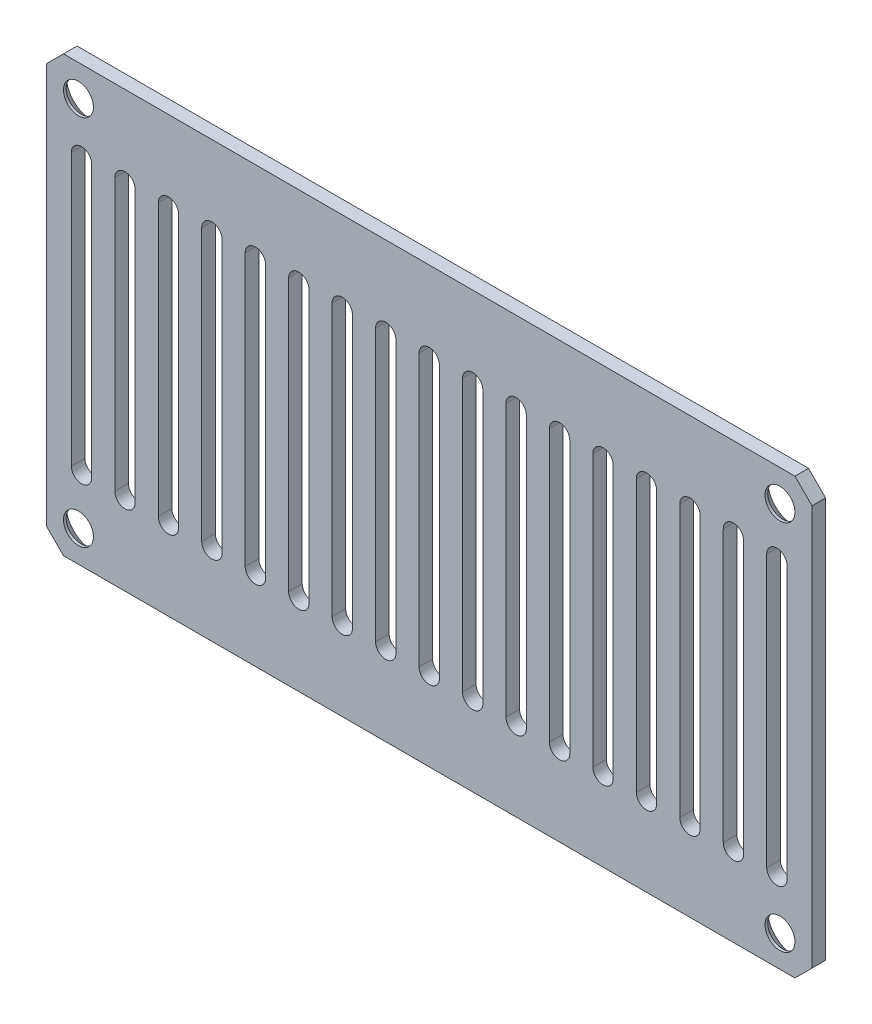
from build123d import *

# Parameters (mm, degrees)
SKETCH1_W           = 89.5
SKETCH1_H           = 50.8
BOSS_EXTRUDE1_DEPTH = 1.5875
CHAMFER1_SIZE       = 2
CUT_EXTRUDE1_DEPTH  = 2.5875
SKETCH3_R           = 1.75
CUT_EXTRUDE2_DEPTH  = 2.5875
CHAMFER2_SIZE       = 1.27


with BuildPart() as part:
    # Sketch1 → Boss-Extrude1 (new body)
    with BuildSketch(Plane.XY):
        with Locations((44.75, 25.4)):
            Rectangle(SKETCH1_W, SKETCH1_H)
    extrude(amount=BOSS_EXTRUDE1_DEPTH)

    # Chamfer1
    chamfer1_edges = [part.edges().sort_by_distance(p)[0] for p in [
        (0, 50.8, 0.79375),
        (89.5, 50.8, 0.79375),
        (89.5, 0, 0.79375),
        (0, 0, 0.79375),
    ]]
    chamfer(chamfer1_edges, length=CHAMFER1_SIZE)

    # Sketch2 → Cut-Extrude1 (cut, through all)
    with BuildSketch(Plane(origin=(0, 0, 0), x_dir=(-1, 0, 0), z_dir=(0, 0, -1))):
        with BuildLine():
            Line((-43.559375, 41.275), (-43.559375, 9.525))
            ThreePointArc((-43.559375, 9.525), (-44.75, 8.334375), (-45.940625, 9.525))
            Line((-45.940625, 9.525), (-45.940625, 41.275))
            ThreePointArc((-45.940625, 41.275), (-44.75, 42.465625), (-43.559375, 41.275))
        make_face()
        with BuildLine():
            Line((-38.479375, 41.275), (-38.479375, 9.525))
            ThreePointArc((-38.479375, 9.525), (-39.67, 8.334375), (-40.860625, 9.525))
            Line((-40.860625, 9.525), (-40.860625, 41.275))
            ThreePointArc((-40.860625, 41.275), (-39.67, 42.465625), (-38.479375, 41.275))
        make_face()
        with BuildLine():
            Line((-33.399375, 41.275), (-33.399375, 9.525))
            ThreePointArc((-33.399375, 9.525), (-34.59, 8.334375), (-35.780625, 9.525))
            Line((-35.780625, 9.525), (-35.780625, 41.275))
            ThreePointArc((-35.780625, 41.275), (-34.59, 42.465625), (-33.399375, 41.275))
        make_face()
        with BuildLine():
            Line((-28.319375, 41.275), (-28.319375, 9.525))
            ThreePointArc((-28.319375, 9.525), (-29.51, 8.334375), (-30.700625, 9.525))
            Line((-30.700625, 9.525), (-30.700625, 41.275))
            ThreePointArc((-30.700625, 41.275), (-29.51, 42.465625), (-28.319375, 41.275))
        make_face()
        with BuildLine():
            Line((-23.239375, 41.275), (-23.239375, 9.525))
            ThreePointArc((-23.239375, 9.525), (-24.43, 8.334375), (-25.620625, 9.525))
            Line((-25.620625, 9.525), (-25.620625, 41.275))
            ThreePointArc((-25.620625, 41.275), (-24.43, 42.465625), (-23.239375, 41.275))
        make_face()
        with BuildLine():
            Line((-18.159375, 41.275), (-18.159375, 9.525))
            ThreePointArc((-18.159375, 9.525), (-19.35, 8.334375), (-20.540625, 9.525))
            Line((-20.540625, 9.525), (-20.540625, 41.275))
            ThreePointArc((-20.540625, 41.275), (-19.35, 42.465625), (-18.159375, 41.275))
        make_face()
        with BuildLine():
            Line((-13.079375, 41.275), (-13.079375, 9.525))
            ThreePointArc((-13.079375, 9.525), (-14.27, 8.334375), (-15.460625, 9.525))
            Line((-15.460625, 9.525), (-15.460625, 41.275))
            ThreePointArc((-15.460625, 41.275), (-14.27, 42.465625), (-13.079375, 41.275))
        make_face()
        with BuildLine():
            Line((-7.999375, 41.275), (-7.999375, 9.525))
            ThreePointArc((-7.999375, 9.525), (-9.19, 8.334375), (-10.380625, 9.525))
            Line((-10.380625, 9.525), (-10.380625, 41.275))
            ThreePointArc((-10.380625, 41.275), (-9.19, 42.465625), (-7.999375, 41.275))
        make_face()
        with BuildLine():
            Line((-2.919375, 41.275), (-2.919375, 9.525))
            ThreePointArc((-2.919375, 9.525), (-4.11, 8.334375), (-5.300625, 9.525))
            Line((-5.300625, 9.525), (-5.300625, 41.275))
            ThreePointArc((-5.300625, 41.275), (-4.11, 42.465625), (-2.919375, 41.275))
        make_face()
        with BuildLine():
            Line((-48.639375, 41.275), (-48.639375, 9.525))
            ThreePointArc((-48.639375, 9.525), (-49.83, 8.334375), (-51.020625, 9.525))
            Line((-51.020625, 9.525), (-51.020625, 41.275))
            ThreePointArc((-51.020625, 41.275), (-49.83, 42.465625), (-48.639375, 41.275))
        make_face()
        with BuildLine():
            Line((-53.719375, 41.275), (-53.719375, 9.525))
            ThreePointArc((-53.719375, 9.525), (-54.91, 8.334375), (-56.100625, 9.525))
            Line((-56.100625, 9.525), (-56.100625, 41.275))
            ThreePointArc((-56.100625, 41.275), (-54.91, 42.465625), (-53.719375, 41.275))
        make_face()
        with BuildLine():
            Line((-58.799375, 41.275), (-58.799375, 9.525))
            ThreePointArc((-58.799375, 9.525), (-59.99, 8.334375), (-61.180625, 9.525))
            Line((-61.180625, 9.525), (-61.180625, 41.275))
            ThreePointArc((-61.180625, 41.275), (-59.99, 42.465625), (-58.799375, 41.275))
        make_face()
        with BuildLine():
            Line((-63.879375, 41.275), (-63.879375, 9.525))
            ThreePointArc((-63.879375, 9.525), (-65.07, 8.334375), (-66.260625, 9.525))
            Line((-66.260625, 9.525), (-66.260625, 41.275))
            ThreePointArc((-66.260625, 41.275), (-65.07, 42.465625), (-63.879375, 41.275))
        make_face()
        with BuildLine():
            Line((-68.959375, 41.275), (-68.959375, 9.525))
            ThreePointArc((-68.959375, 9.525), (-70.15, 8.334375), (-71.340625, 9.525))
            Line((-71.340625, 9.525), (-71.340625, 41.275))
            ThreePointArc((-71.340625, 41.275), (-70.15, 42.465625), (-68.959375, 41.275))
        make_face()
        with BuildLine():
            Line((-74.039375, 41.275), (-74.039375, 9.525))
            ThreePointArc((-74.039375, 9.525), (-75.23, 8.334375), (-76.420625, 9.525))
            Line((-76.420625, 9.525), (-76.420625, 41.275))
            ThreePointArc((-76.420625, 41.275), (-75.23, 42.465625), (-74.039375, 41.275))
        make_face()
        with BuildLine():
            Line((-79.119375, 41.275), (-79.119375, 9.525))
            ThreePointArc((-79.119375, 9.525), (-80.31, 8.334375), (-81.500625, 9.525))
            Line((-81.500625, 9.525), (-81.500625, 41.275))
            ThreePointArc((-81.500625, 41.275), (-80.31, 42.465625), (-79.119375, 41.275))
        make_face()
        with BuildLine():
            Line((-84.199375, 41.275), (-84.199375, 9.525))
            ThreePointArc((-84.199375, 9.525), (-85.39, 8.334375), (-86.580625, 9.525))
            Line((-86.580625, 9.525), (-86.580625, 41.275))
            ThreePointArc((-86.580625, 41.275), (-85.39, 42.465625), (-84.199375, 41.275))
        make_face()
    extrude(amount=-CUT_EXTRUDE1_DEPTH, mode=Mode.SUBTRACT)

    # Sketch3 → Cut-Extrude2 (cut, through all)
    with BuildSketch(Plane(origin=(0, 0, 0), x_dir=(-1, 0, 0), z_dir=(0, 0, -1))):
        with Locations((-85.75, 47.15)):
            Circle(SKETCH3_R)
        with Locations((-3.75, 47.15)):
            Circle(SKETCH3_R)
        with Locations((-3.75, 3.65)):
            Circle(SKETCH3_R)
        with Locations((-85.75, 3.65)):
            Circle(SKETCH3_R)
    extrude(amount=-CUT_EXTRUDE2_DEPTH, mode=Mode.SUBTRACT)

    # Chamfer2
    chamfer2_edges = [part.edges().sort_by_distance(p)[0] for p in [
        (87.5, 47.15, 0),
        (5.5, 47.15, 0),
        (5.5, 3.65, 0),
        (87.5, 3.65, 0),
    ]]
    chamfer(chamfer2_edges, length=CHAMFER2_SIZE)


solid = part.part
